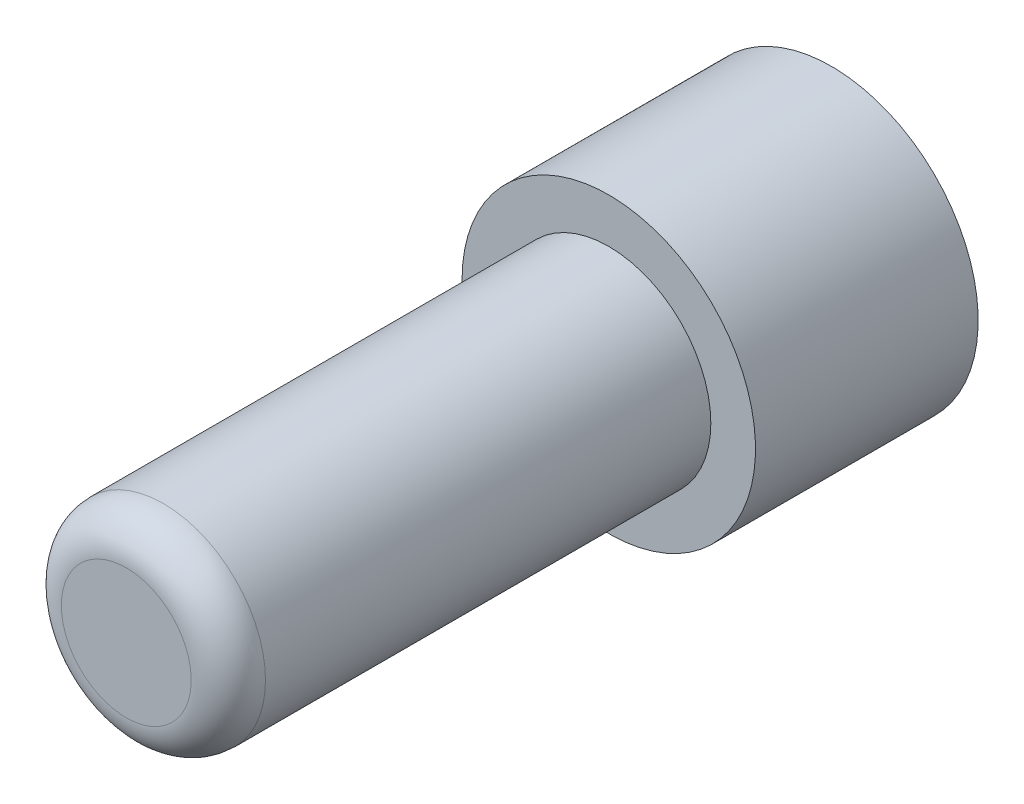
from build123d import *

# Parameters (mm, degrees)
SKETCH1_R                = 2.75
BOSS_EXTRUDE1_DEPTH      = 5
BOSS_EXTRUDE1_DEPTH_BACK = 8
SKETCH2_R                = 3.952847075
BOSS_EXTRUDE2_DEPTH      = 4
SKETCH3_R                = 3.952847075
SKETCH3_R_2              = 2
BOSS_EXTRUDE3_DEPTH      = 2
FILLET1_R                = 1


with BuildPart() as part:
    # Sketch1 → Boss-Extrude1 (new body, two sides)
    with BuildSketch(Plane(origin=(0, 0, 255.707141652), x_dir=(-1, 0, 0), z_dir=(0, 0, -1))) as boss_extrude1_sk:
        with Locations((-95.862602529, 210.063080558)):
            Circle(SKETCH1_R)
    extrude(amount=BOSS_EXTRUDE1_DEPTH)
    extrude(boss_extrude1_sk.sketch, amount=-BOSS_EXTRUDE1_DEPTH_BACK)

    # Sketch2 → Boss-Extrude2 (add)
    with BuildSketch(Plane(origin=(0, 0, 250.707141652), x_dir=(-1, 0, 0), z_dir=(0, 0, -1))):
        with Locations((-95.862602529, 210.063080558)):
            Circle(SKETCH2_R)
    extrude(amount=BOSS_EXTRUDE2_DEPTH)

    # Sketch3 → Boss-Extrude3 (add)
    with BuildSketch(Plane(origin=(0, 0, 246.707141652), x_dir=(-1, 0, 0), z_dir=(0, 0, -1))):
        with Locations((-95.862602529, 210.063080558)):
            Circle(SKETCH3_R)
        with Locations((-95.862602529, 210.063080558)):
            Circle(SKETCH3_R_2, mode=Mode.SUBTRACT)
    extrude(amount=BOSS_EXTRUDE3_DEPTH)

    # Fillet1
    fillet1_edges = [part.edges().sort_by_distance(p)[0] for p in [
        (98.612602529, 210.063080558, 263.707141652),
    ]]
    fillet(fillet1_edges, radius=FILLET1_R)


solid = part.part
